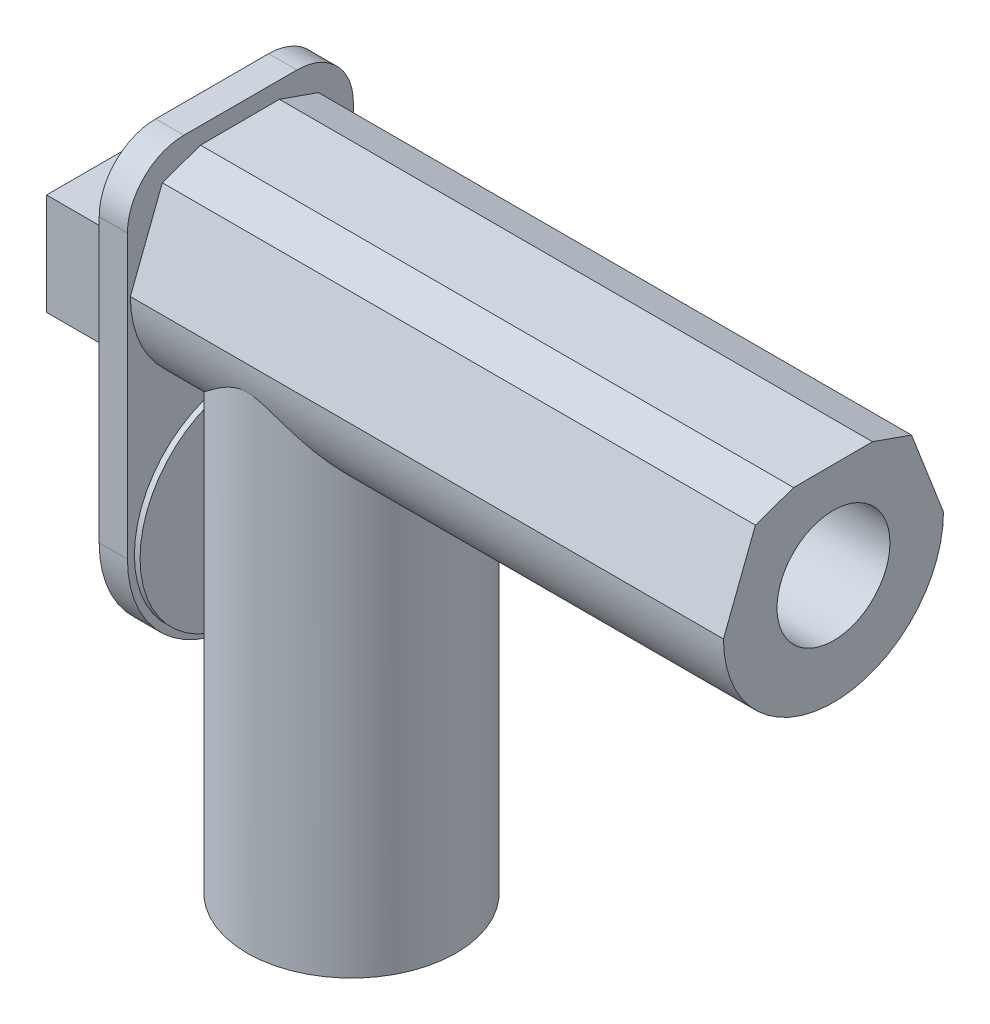
from build123d import *

# Parameters (mm, degrees)
SKETCH_1_W               = 19
SKETCH_1_H               = 18
EXTRUDE_1_DEPTH          = 20
EXTRUDE_2_DEPTH          = 5
SKETCH_4_R               = 18.765633517
EXTRUDE_4_DEPTH          = 1
EXTRUDE_5_DEPTH          = 105
SKETCH_12_R              = 18.5
EXTRUDE_13_DEPTH         = 90
SKETCH_13_R              = 3.5
CUT_EXTRUDE_2_DEPTH      = 20
CUT_EXTRUDE_2_DEPTH_BACK = 40
SKETCH_6_R               = 10
CUT_EXTRUDE_3_DEPTH      = 100


with BuildPart() as part:
    # 草图1 → 凸台-拉伸1 (new body)
    with BuildSketch(Plane.XY):
        with Locations((6.777447397, 42.462092888)):
            Rectangle(SKETCH_1_W, SKETCH_1_H)
    extrude(amount=EXTRUDE_1_DEPTH)

    # 草图2 → 凸台-拉伸2 (add)
    with BuildSketch(Plane(origin=(16.277447397, 0, 0), x_dir=(0, 0, -1), z_dir=(1, 0, 0))):
        with BuildLine():
            Line((-29.676018319, 12.462092888), (-29.676018319, 42.462092888))
            Line((-29.676018319, 42.462092888), (-29.676018319, 62.462092888))
            ThreePointArc((-29.676018319, 62.462092888), (-26.747086131, 69.5331607), (-19.676018319, 72.462092888))
            Line((-19.676018319, 72.462092888), (0.323981681, 72.462092888))
            ThreePointArc((0.323981681, 72.462092888), (7.395049493, 69.5331607), (10.323981681, 62.462092888))
            Line((10.323981681, 62.462092888), (10.323981681, 42.462092888))
            Line((10.323981681, 42.462092888), (10.323981681, 12.462092888))
            ThreePointArc((10.323981681, 12.462092888), (-9.676018319, -7.537907112), (-29.676018319, 12.462092888))
        make_face()
    extrude(amount=EXTRUDE_2_DEPTH)

    # 草图4 → 凸台-拉伸4 (add)
    with BuildSketch(Plane(origin=(21.277447397, 0, 0), x_dir=(0, 0, -1), z_dir=(1, 0, 0))):
        with Locations((-9.676018319, 12.462092888)):
            Circle(SKETCH_4_R)
    extrude(amount=EXTRUDE_4_DEPTH)

    # 草图5 → 凸台-拉伸5 (add)
    with BuildSketch(Plane(origin=(21.277447397, 0, 0), x_dir=(0, 0, -1), z_dir=(1, 0, 0))):
        with BuildLine():
            Line((-29.154370976, 52.462092888), (-23.49669222, 67.083579023))
            Line((-23.49669222, 67.083579023), (-16.725326826, 69.463174846))
            Line((-16.725326826, 69.463174846), (-2.765681369, 69.512012284))
            Line((-2.765681369, 69.512012284), (4.144655582, 67.083579023))
            Line((4.144655582, 67.083579023), (9.802334338, 52.462092888))
            ThreePointArc((9.802334338, 52.462092888), (-9.676018319, 32.983740231), (-29.154370976, 52.462092888))
        make_face()
    extrude(amount=EXTRUDE_5_DEPTH)

    # 草图12 → 凸台-拉伸13 (add)
    with BuildSketch(Plane(origin=(0, 51.462092888, 0), x_dir=(1, 0, 0), z_dir=(0, 1, 0))):
        with Locations((41.277447397, -10)):
            Circle(SKETCH_12_R)
    extrude(amount=-EXTRUDE_13_DEPTH)

    # 草图13 → 切除-拉伸2 (cut, two sides)
    with BuildSketch(Plane.XZ.offset(-33.462092888)) as cut_extrude_2_sk:
        with Locations((7.557005132, 10)):
            Circle(SKETCH_13_R)
    extrude(amount=CUT_EXTRUDE_2_DEPTH, mode=Mode.SUBTRACT)
    extrude(cut_extrude_2_sk.sketch, amount=-CUT_EXTRUDE_2_DEPTH_BACK, mode=Mode.SUBTRACT)

    # 草图6 → 切除-拉伸3 (cut)
    with BuildSketch(Plane(origin=(126.277447397, 0, 0), x_dir=(0, 0, -1), z_dir=(1, 0, 0))):
        with Locations((-9.676018319, 52.462092888)):
            Circle(SKETCH_6_R)
    extrude(amount=-CUT_EXTRUDE_3_DEPTH, mode=Mode.SUBTRACT)


solid = part.part
